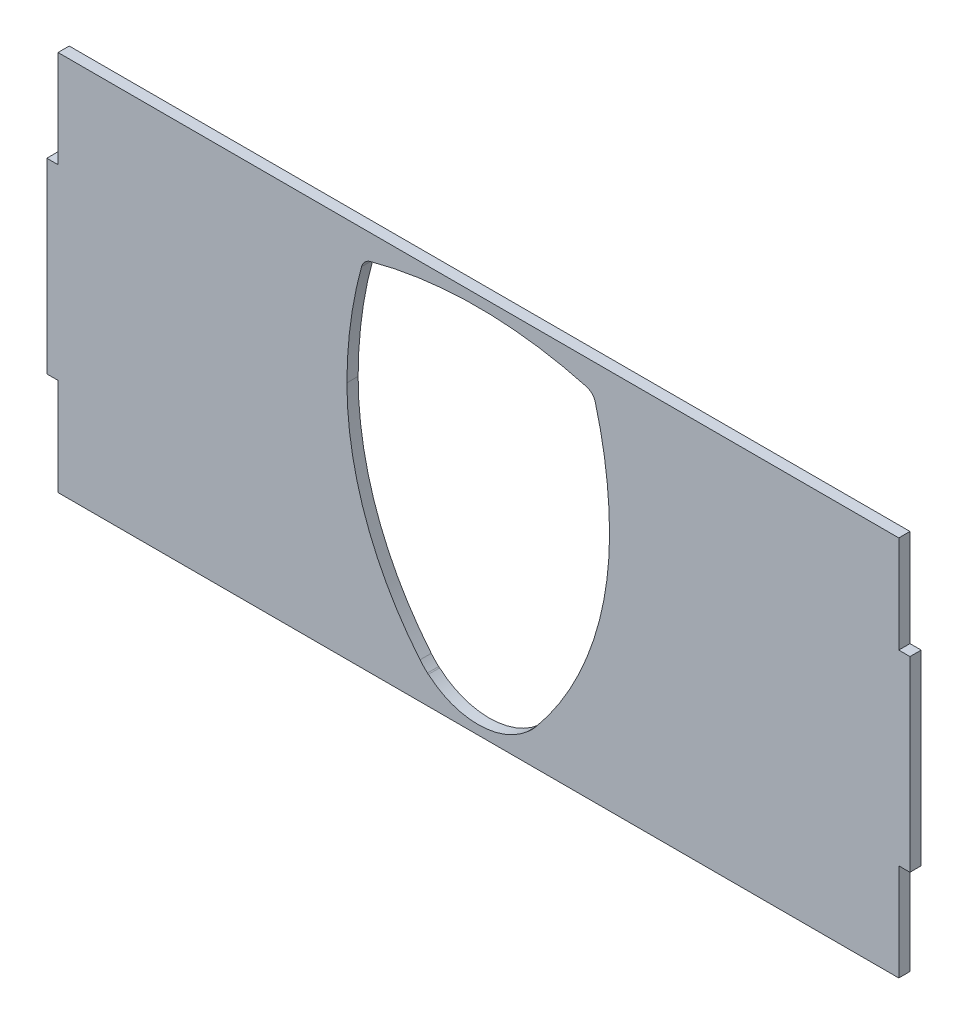
from build123d import *

# Parameters (mm, degrees)
BOSS_EXTRUDE1_DEPTH = 3


with BuildPart() as part:
    # Sketch1 → Boss-Extrude1 (new body)
    with BuildSketch(Plane.XY):
        Polygon((-112.34268018, 49.584121622), (-112.34268018, 23.584121622), (-115.34268018, 23.584121622), (-115.34268018, -26.415878378), (-112.34268018, -26.415878378), (-112.34268018, -52.415878378), (112.65731982, -52.415878378), (112.65731982, -26.415878378), (115.65731982, -26.415878378), (115.65731982, 23.584121622), (112.65731982, 23.584121622), (112.65731982, 49.584121622), align=None)
        with BuildLine():
            Line((13.274286272, -45.008836488), (13.301852176, -45.03203797))
            add(Edge.make_bspline(
                [(13.301852176, -45.03203797), (13.302434824, -45.031895887), (13.303594926, -45.031612989), (13.310345597, -45.026788399), (13.327424294, -45.013559601), (13.368373413, -44.979806794), (13.432345907, -44.924692433), (13.489247142, -44.874546261), (13.518732521, -44.84808225), (13.533463875, -44.834860418)],
                knots=[0, 0, 0, 0, 0.083775212, 0.166803477, 0.250583378, 0.499711324, 0.748903893, 0.874548479, 1, 1, 1, 1], degree=3))
            ThreePointArc((13.533463875, -44.834860418), (14.561847159, -43.83964014), (15.516962395, -42.773905432))
            ThreePointArc((15.516962395, -42.773905432), (30.145326147, -17.328936846), (35.253292189, 11.573383741))
            ThreePointArc((35.253292189, 11.573383741), (34.303607008, 26.14987852), (31.427393187, 40.471313366))
            ThreePointArc((31.427393187, 40.471313366), (30.556136604, 41.977838946), (29.052246095, 42.853636122))
            ThreePointArc((29.052246095, 42.853636122), (0.16598909, 46.766690687), (-28.731940535, 42.940791684))
            ThreePointArc((-28.731940535, 42.940791684), (-30.238466115, 42.069535101), (-31.114263292, 40.565644593))
            ThreePointArc((-31.114263292, 40.565644593), (-34.033665807, 26.252951242), (-35.027317855, 11.679387588))
            ThreePointArc((-35.027317855, 11.679387588), (-30.00656127, -17.238210094), (-15.455020905, -42.727190564))
            ThreePointArc((-15.455020905, -42.727190564), (-14.50312489, -43.795801606), (-13.477748449, -44.794119559))
            add(Edge.make_bspline(
                [(-13.477748449, -44.794119559), (-13.467950877, -44.802979196), (-13.448447729, -44.820615282), (-13.419486181, -44.846490582), (-13.372927905, -44.887713721), (-13.313203528, -44.93946889), (-13.269741808, -44.975508675), (-13.250245048, -44.990563249), (-13.247902102, -44.991518213), (-13.246732606, -44.991994889)],
                knots=[0, 0, 0, 0, 0.083817862, 0.166848714, 0.250507589, 0.499664298, 0.748829297, 0.874626478, 1, 1, 1, 1], degree=3))
            Line((-13.246732606, -44.991994889), (-13.219096838, -44.968876668))
            ThreePointArc((-13.219096838, -44.968876668), (0.020078677, -49.971995234), (13.274286272, -45.008836488))
        make_face(mode=Mode.SUBTRACT)
    extrude(amount=BOSS_EXTRUDE1_DEPTH)


solid = part.part
